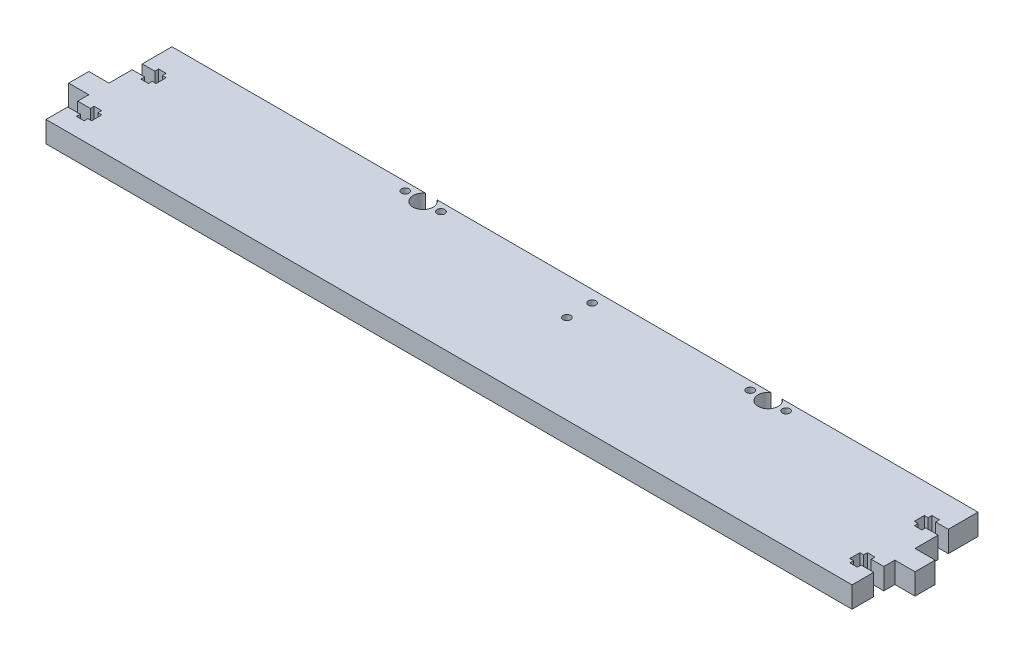
from build123d import *

# Parameters (mm, degrees)
SKETCH1_R           = 1.5
BOSS_EXTRUDE1_DEPTH = 8.4


with BuildPart() as part:
    # Sketch1 → Boss-Extrude1 (new body)
    with BuildSketch(Plane(origin=(0, 0, 0), x_dir=(1, 0, 0), z_dir=(0, 1, 0))):
        with BuildLine():
            Line((-160, 25), (-59.260530911, 25))
            ThreePointArc((-59.260530911, 25), (-57, 17.7), (-54.739469089, 25))
            Line((-54.739469089, 25), (77.739469089, 25))
            ThreePointArc((77.739469089, 25), (80, 17.7), (82.260530911, 25))
            Line((82.260530911, 25), (160, 25))
            Line((160, 25), (160, 13.2))
            Line((160, 13.2), (155, 13.2))
            Line((155, 13.2), (155, 14.7))
            Line((155, 14.7), (152, 14.7))
            Line((152, 14.7), (152, 13.2))
            Line((152, 13.2), (150.5, 13.2))
            Line((150.5, 13.2), (150.5, 9.2))
            Line((150.5, 9.2), (152, 9.2))
            Line((152, 9.2), (152, 7.7))
            Line((152, 7.7), (155, 7.7))
            Line((155, 7.7), (155, 9.2))
            Line((155, 9.2), (160, 9.2))
            Line((160, 9.2), (160, 0))
            Line((160, 0), (168, 0))
            Line((168, 0), (168, -8))
            Line((168, -8), (160, -8))
            Line((160, -8), (160, -12.4))
            Line((160, -12.4), (155, -12.4))
            Line((155, -12.4), (155, -10.9))
            Line((155, -10.9), (152, -10.9))
            Line((152, -10.9), (152, -12.4))
            Line((152, -12.4), (150.5, -12.4))
            Line((150.5, -12.4), (150.5, -16.4))
            Line((150.5, -16.4), (152, -16.4))
            Line((152, -16.4), (152, -17.9))
            Line((152, -17.9), (155, -17.9))
            Line((155, -17.9), (155, -16.4))
            Line((155, -16.4), (160, -16.4))
            Line((160, -16.4), (160, -25))
            Line((160, -25), (-160, -25))
            Line((-160, -25), (-160, -16.4))
            Line((-160, -16.4), (-155, -16.4))
            Line((-155, -16.4), (-155, -17.9))
            Line((-155, -17.9), (-152, -17.9))
            Line((-152, -17.9), (-152, -16.4))
            Line((-152, -16.4), (-150.5, -16.4))
            Line((-150.5, -16.4), (-150.5, -12.4))
            Line((-150.5, -12.4), (-152, -12.4))
            Line((-152, -12.4), (-152, -10.9))
            Line((-152, -10.9), (-155, -10.9))
            Line((-155, -10.9), (-155, -12.4))
            Line((-155, -12.4), (-160, -12.4))
            Line((-160, -12.4), (-160, -8))
            Line((-160, -8), (-168, -8))
            Line((-168, -8), (-168, 0))
            Line((-168, 0), (-160, 0))
            Line((-160, 0), (-160, 9.2))
            Line((-160, 9.2), (-155, 9.2))
            Line((-155, 9.2), (-155, 7.7))
            Line((-155, 7.7), (-152, 7.7))
            Line((-152, 7.7), (-152, 9.2))
            Line((-152, 9.2), (-150.5, 9.2))
            Line((-150.5, 9.2), (-150.5, 13.2))
            Line((-150.5, 13.2), (-152, 13.2))
            Line((-152, 13.2), (-152, 14.7))
            Line((-152, 14.7), (-155, 14.7))
            Line((-155, 14.7), (-155, 13.2))
            Line((-155, 13.2), (-160, 13.2))
            Line((-160, 13.2), (-160, 25))
        make_face()
        with Locations((11.5, 20.3)):
            Circle(SKETCH1_R, mode=Mode.SUBTRACT)
        with Locations((11.5, 10.3)):
            Circle(SKETCH1_R, mode=Mode.SUBTRACT)
        with Locations((87.1, 21.7)):
            Circle(SKETCH1_R, mode=Mode.SUBTRACT)
        with Locations((72.9, 21.7)):
            Circle(SKETCH1_R, mode=Mode.SUBTRACT)
        with Locations((-49.9, 21.7)):
            Circle(SKETCH1_R, mode=Mode.SUBTRACT)
        with Locations((-64.1, 21.7)):
            Circle(SKETCH1_R, mode=Mode.SUBTRACT)
    extrude(amount=BOSS_EXTRUDE1_DEPTH)


solid = part.part
